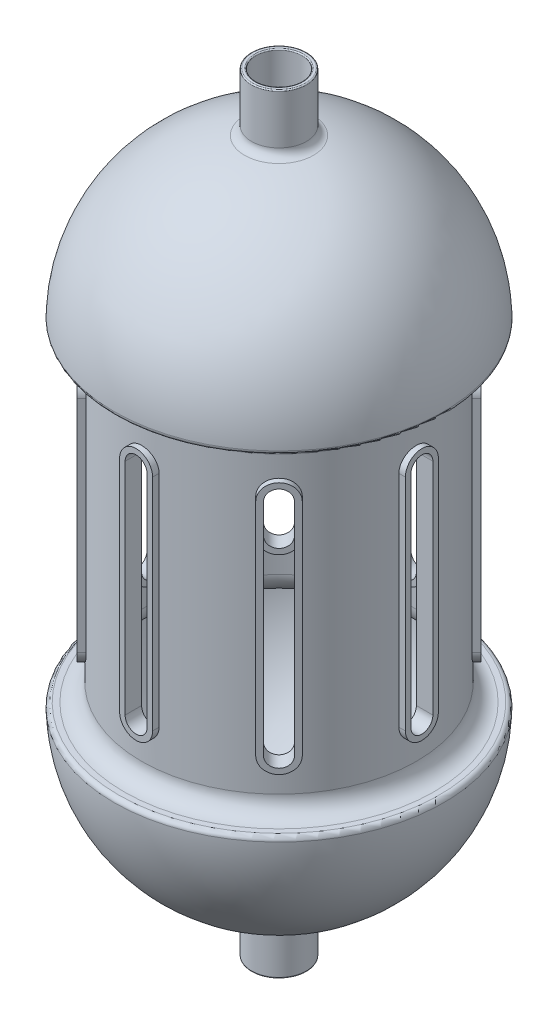
from build123d import *

# Parameters (mm, degrees)
BOSS_EXTRUDE1_START = -10
BOSS_EXTRUDE1_DEPTH = 15
CUT_EXTRUDE4_DEPTH  = 15
CIRPATTERN1_COUNT   = 8


with BuildPart() as part:
    # Sketch2 → Revolve2 (revolve)
    with BuildSketch(Plane.XY):
        with BuildLine():
            Line((141, -155), (142.828568571, -155))
            ThreePointArc((142.828568571, -155), (144.27698222, -155.620834346), (144.826170928, -157.097902098))
            ThreePointArc((144.826170928, -157.097902098), (109.532675904, -245.013645911), (27.483660131, -292.3715155))
            ThreePointArc((27.483660131, -292.3715155), (22.830286921, -295.133889209), (21, -300.226495666))
            Line((21, -300.226495666), (21, -349))
            ThreePointArc((21, -349), (21.292893219, -349.707106781), (22, -350))
            Line((22, -350), (24, -350))
            ThreePointArc((24, -350), (24.707106781, -349.707106781), (25, -349))
            Line((25, -349), (25, -304.515371404))
            ThreePointArc((25, -304.515371404), (26.780390342, -299.483825349), (31.329113924, -296.691808295))
            ThreePointArc((31.329113924, -296.691808295), (115.314266277, -245.930287151), (149.943693692, -154.109589041))
            ThreePointArc((149.943693692, -154.109589041), (148.812106089, -151.210587532), (145.945195193, -150))
            Line((145.945195193, -150), (141, -150))
            ThreePointArc((141, -150), (129.686291501, -145.313708499), (125, -134))
            Line((125, -134), (125, 134))
            ThreePointArc((125, 134), (129.686291501, 145.313708499), (141, 150))
            Line((141, 150), (145.945195193, 150))
            ThreePointArc((145.945195193, 150), (148.812106089, 151.210587532), (149.943693692, 154.109589041))
            ThreePointArc((149.943693692, 154.109589041), (115.314266277, 245.930287151), (31.329113924, 296.691808295))
            ThreePointArc((31.329113924, 296.691808295), (26.780390342, 299.483825349), (25, 304.515371404))
            Line((25, 304.515371404), (25, 349))
            ThreePointArc((25, 349), (24.707106781, 349.707106781), (24, 350))
            Line((24, 350), (22, 350))
            ThreePointArc((22, 350), (21.292893219, 349.707106781), (21, 349))
            Line((21, 349), (21, 300.226495666))
            ThreePointArc((21, 300.226495666), (22.830286921, 295.133889209), (27.483660131, 292.3715155))
            ThreePointArc((27.483660131, 292.3715155), (109.532675904, 245.013645911), (144.826170928, 157.097902098))
            ThreePointArc((144.826170928, 157.097902098), (144.27698222, 155.620834346), (142.828568571, 155))
            Line((142.828568571, 155), (141, 155))
            ThreePointArc((141, 155), (126.150757595, 148.849242405), (120, 134))
            Line((120, 134), (120, -134))
            ThreePointArc((120, -134), (126.150757595, -148.849242405), (141, -155))
        make_face()
    revolve(axis=Axis((0, 349, 0), (0, -1, 0)))

    # Sketch4 → Boss-Extrude1 (add)
    with BuildSketch(Plane.ZY.offset(125).offset(BOSS_EXTRUDE1_START)):
        with BuildLine():
            Line((-15, -100), (-15, 100))
            ThreePointArc((-15, 100), (0, 115), (15, 100))
            Line((15, 100), (15, -100))
            ThreePointArc((15, -100), (0, -115), (-15, -100))
        make_face()
    boss_extrude1 = extrude(amount=BOSS_EXTRUDE1_DEPTH)

    # Sketch5 → Cut-Extrude4 (cut)
    with BuildSketch(Plane.ZY.offset(130)):
        with BuildLine():
            Line((-10, -100), (-10, 100))
            ThreePointArc((-10, 100), (0, 110), (10, 100))
            Line((10, 100), (10, -100))
            ThreePointArc((10, -100), (0, -110), (-10, -100))
        make_face()
    cut_extrude4 = extrude(amount=-CUT_EXTRUDE4_DEPTH, mode=Mode.SUBTRACT)

    # CirPattern1: Boss-Extrude1, Cut-Extrude4 ×8 about axis
    cirpattern1_axis = Axis((0, 0, 0), (0, 1, 0))
    for i in range(1, CIRPATTERN1_COUNT):
        add(boss_extrude1.rotate(cirpattern1_axis, i * 360 / CIRPATTERN1_COUNT))
        add(cut_extrude4.rotate(cirpattern1_axis, i * 360 / CIRPATTERN1_COUNT), mode=Mode.SUBTRACT)


solid = part.part
